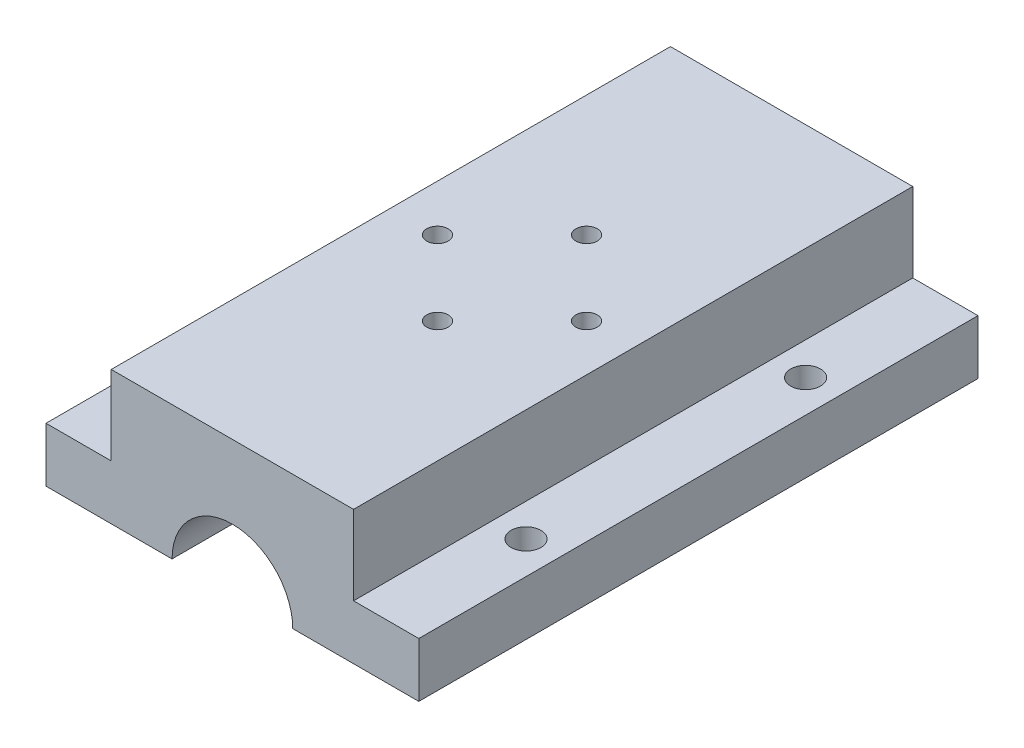
from build123d import *

# Parameters (mm, degrees)
BOSS_EXTRUDE6_DEPTH = 60
SKETCH9_R           = 1.6
CUT_EXTRUDE3_DEPTH  = 50
SKETCH10_R          = 1.15
CUT_EXTRUDE5_DEPTH  = 22.05
SKETCH11_W          = 7
SKETCH11_H          = 60
SKETCH11_R          = 1.6
BOSS_EXTRUDE7_DEPTH = 3
SKETCH12_W          = 7
SKETCH12_H          = 60
SKETCH12_R          = 1.6
BOSS_EXTRUDE8_DEPTH = 3
SKETCH16_R          = 2.5
CUT_EXTRUDE9_DEPTH  = 8.75
SKETCH17_R          = 2.5
CUT_EXTRUDE10_DEPTH = 8.75


with BuildPart() as part:
    # Sketch2 → Boss-Extrude6 (new body)
    with BuildSketch(Plane.XY):
        with BuildLine():
            ThreePointArc((6.475, 0), (0, 6.475), (-6.475, 0))
            Line((-6.475, 0), (-20, 0))
            Line((-20, 0), (-20, 2.847591854))
            Line((-20, 2.847591854), (-13, 2.847591854))
            Line((-13, 2.847591854), (-13, 14.347591854))
            Line((-13, 14.347591854), (13, 14.347591854))
            Line((13, 14.347591854), (13, 2.847591854))
            Line((13, 2.847591854), (20, 2.847591854))
            Line((20, 2.847591854), (20, 0))
            Line((20, 0), (6.475, 0))
        make_face()
    extrude(amount=BOSS_EXTRUDE6_DEPTH)

    # Sketch9 → Cut-Extrude3 (cut)
    with BuildSketch(Plane(origin=(0, 2.847591854, 0), x_dir=(1, 0, 0), z_dir=(0, 1, 0))):
        with Locations((-16.5, -15)):
            Circle(SKETCH9_R)
        with Locations((-16.5, -45)):
            Circle(SKETCH9_R)
        with Locations((16.5, -15)):
            Circle(SKETCH9_R)
        with Locations((16.5, -45)):
            Circle(SKETCH9_R)
    extrude(amount=-CUT_EXTRUDE3_DEPTH, mode=Mode.SUBTRACT)

    # Sketch10 → Cut-Extrude5 (cut)
    with BuildSketch(Plane(origin=(0, 14.347591854, 0), x_dir=(1, 0, 0), z_dir=(0, 1, 0))):
        with Locations((0, -22)):
            Circle(SKETCH10_R)
        with Locations((8, -30)):
            Circle(SKETCH10_R)
        with Locations((-8, -30)):
            Circle(SKETCH10_R)
        with Locations((0, -38)):
            Circle(SKETCH10_R)
    extrude(amount=-CUT_EXTRUDE5_DEPTH, mode=Mode.SUBTRACT)

    # Sketch11 → Boss-Extrude7 (add)
    with BuildSketch(Plane(origin=(0, 2.847591854, 0), x_dir=(1, 0, 0), z_dir=(0, 1, 0))):
        with Locations((16.5, -30)):
            Rectangle(SKETCH11_W, SKETCH11_H)
        with Locations((16.5, -45)):
            Circle(SKETCH11_R, mode=Mode.SUBTRACT)
        with Locations((16.5, -15)):
            Circle(SKETCH11_R, mode=Mode.SUBTRACT)
    extrude(amount=BOSS_EXTRUDE7_DEPTH)

    # Sketch12 → Boss-Extrude8 (add)
    with BuildSketch(Plane(origin=(0, 2.847591854, 0), x_dir=(1, 0, 0), z_dir=(0, 1, 0))):
        with Locations((-16.5, -30)):
            Rectangle(SKETCH12_W, SKETCH12_H)
        with Locations((-16.5, -45)):
            Circle(SKETCH12_R, mode=Mode.SUBTRACT)
        with Locations((-16.5, -15)):
            Circle(SKETCH12_R, mode=Mode.SUBTRACT)
    extrude(amount=BOSS_EXTRUDE8_DEPTH)

    # Sketch16 → Cut-Extrude9 (cut)
    with BuildSketch(Plane(origin=(0, 0, 0), x_dir=(-1, 0, 0), z_dir=(0, -1, 0))):
        with Locations((0, -22)):
            Circle(SKETCH16_R)
        with Locations((0, -38)):
            Circle(SKETCH16_R)
    extrude(amount=-CUT_EXTRUDE9_DEPTH, mode=Mode.SUBTRACT)

    # Sketch17 → Cut-Extrude10 (cut)
    with BuildSketch(Plane(origin=(0, 0, 0), x_dir=(-1, 0, 0), z_dir=(0, -1, 0))):
        with Locations((-8, -30)):
            Circle(SKETCH17_R)
        with Locations((8, -30)):
            Circle(SKETCH17_R)
    extrude(amount=-CUT_EXTRUDE10_DEPTH, mode=Mode.SUBTRACT)


solid = part.part
